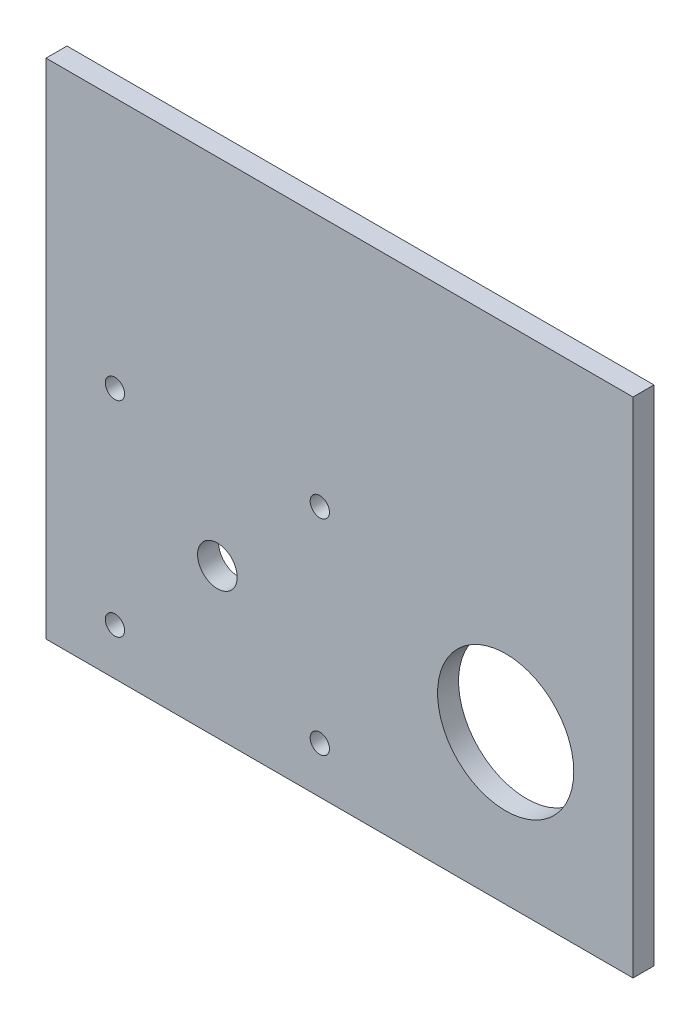
from build123d import *

# Parameters (mm, degrees)
SKETCH1_W           = 88.9
SKETCH1_H           = 76.2
SKETCH1_R           = 1.4605
SKETCH1_R_2         = 3
SKETCH1_R_3         = 10.3124
BOSS_EXTRUDE1_DEPTH = 3.175


with BuildPart() as part:
    # Sketch1 → Boss-Extrude1 (new body)
    with BuildSketch(Plane.XY):
        with Locations((44.45, 38.1)):
            Rectangle(SKETCH1_W, SKETCH1_H)
        with Locations((10.43525, 38.1)):
            Circle(SKETCH1_R, mode=Mode.SUBTRACT)
        with Locations((41.46525, 38.1)):
            Circle(SKETCH1_R, mode=Mode.SUBTRACT)
        with Locations((41.46525, 7.07)):
            Circle(SKETCH1_R, mode=Mode.SUBTRACT)
        with Locations((10.43525, 7.07)):
            Circle(SKETCH1_R, mode=Mode.SUBTRACT)
        with Locations((25.95025, 22.585)):
            Circle(SKETCH1_R_2, mode=Mode.SUBTRACT)
        with Locations((69.61285, 22.585)):
            Circle(SKETCH1_R_3, mode=Mode.SUBTRACT)
    extrude(amount=BOSS_EXTRUDE1_DEPTH)


solid = part.part
